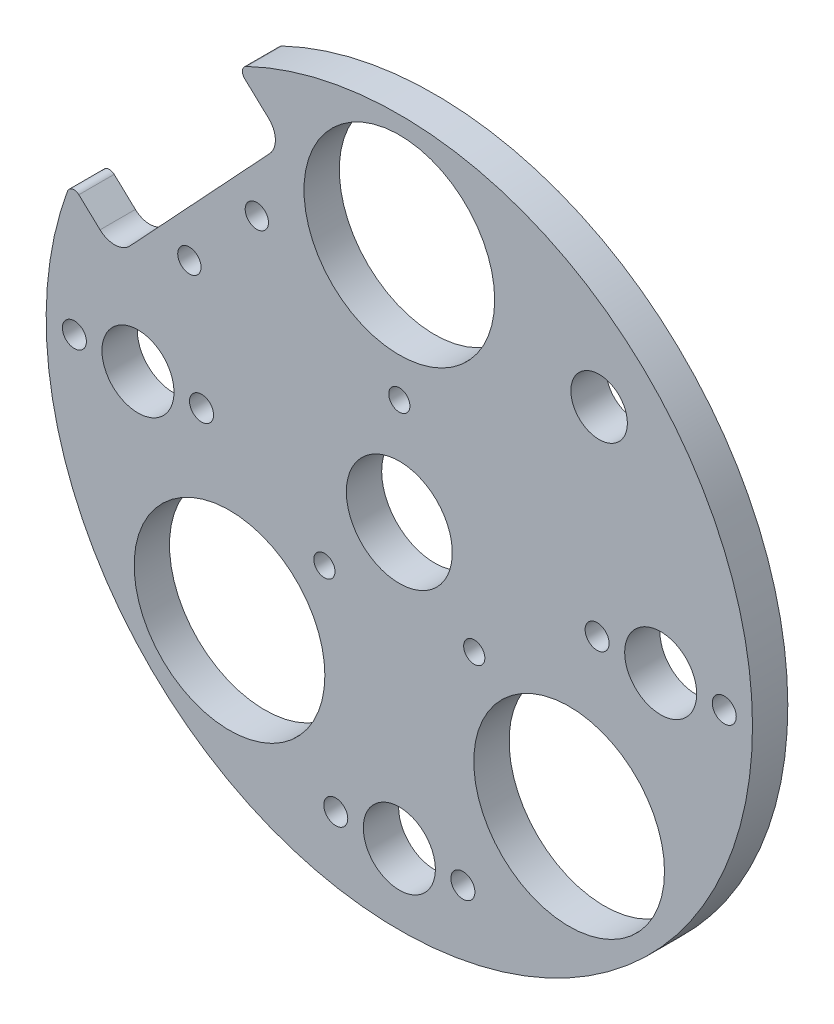
from build123d import *

# Parameters (mm, degrees)
SKETCH1_R                    = 50
BOSS_EXTRUDE1_DEPTH          = 5
F_15_0_15_DIAMETER_HOLE1_D   = 15
F_10_2_10_2_DIAMETER_HOLE1_D = 10.2
M3_CLEARANCE_HOLE1_D         = 3.4
SKETCH9_R                    = 13.5
SKETCH9_R_2                  = 1.5
CUT_EXTRUDE1_DEPTH           = 10
SKETCH10_R                   = 1.65
CUT_EXTRUDE2_DEPTH           = 10
SKETCH13_R                   = 4
CUT_EXTRUDE6_DEPTH           = 10
FILLET1_R                    = 1


with BuildPart() as part:
    # Sketch1 → Boss-Extrude1 (new body)
    with BuildSketch(Plane.XY):
        Circle(SKETCH1_R)
    extrude(amount=BOSS_EXTRUDE1_DEPTH)

    # Ø15.0 (15) Diameter Hole1 (through all)
    with Locations(Plane(origin=(0, 0, 0), x_dir=(-1, 0, 0), z_dir=(0, 0, -1))):
        with Locations((0, 0)):
            Hole(F_15_0_15_DIAMETER_HOLE1_D / 2)

    # Ø10.2 (10.2) Diameter Hole1 (through all)
    with Locations(Plane(origin=(0, 0, 0), x_dir=(-1, 0, 0), z_dir=(0, 0, -1))):
        with Locations((37, 0), (-37, 0), (0, -40)):
            Hole(F_10_2_10_2_DIAMETER_HOLE1_D / 2)

    # M3 Clearance Hole1 (through all)
    with Locations(Plane.XY.offset(5)):
        with Locations((46, 0), (28, 0), (9, -40), (-9, -40), (-46, 0), (-28, 0)):
            Hole(M3_CLEARANCE_HOLE1_D / 2)

    # Sketch9 → Cut-Extrude1 (cut)
    with BuildSketch(Plane.XY.offset(5)):
        with Locations((24.04163056, -24.04163056)):
            Circle(SKETCH9_R)
        with Locations((10.606601718, -10.606601718)):
            Circle(SKETCH9_R_2)
        with Locations((-24.04163056, -24.04163056)):
            Circle(SKETCH9_R)
        with Locations((-10.606601718, -10.606601718)):
            Circle(SKETCH9_R_2)
        with Locations((0, 34)):
            Circle(SKETCH9_R)
        with Locations((0, 15)):
            Circle(SKETCH9_R_2)
    extrude(amount=-CUT_EXTRUDE1_DEPTH, mode=Mode.SUBTRACT)

    # Sketch10 → Cut-Extrude2 (cut)
    with BuildSketch(Plane.XY.offset(5)):
        with Locations((-20.17442319, 27.477446333)):
            Circle(SKETCH10_R)
        with Locations((-29.722400231, 17.23849451)):
            Circle(SKETCH10_R)
        with BuildLine():
            Line((-27.274837591, 48.455628221), (-18.498593172, 40.2716479))
            ThreePointArc((-18.498593172, 40.2716479), (-17.546415771, 38.182285285), (-18.350527147, 36.031591715))
            Line((-18.350527147, 36.031591715), (-38.128479589, 14.822334368))
            ThreePointArc((-38.128479589, 14.822334368), (-40.217842204, 13.870156967), (-42.368535774, 14.674268343))
            Line((-42.368535774, 14.674268343), (-51.144780194, 22.858248664))
            Line((-51.144780194, 22.858248664), (-27.274837591, 48.455628221))
        make_face()
    extrude(amount=-CUT_EXTRUDE2_DEPTH, mode=Mode.SUBTRACT)

    # Sketch13 → Cut-Extrude6 (cut)
    with BuildSketch(Plane.XY.offset(5)):
        with Locations((28.284271247, 28.284271247)):
            Circle(SKETCH13_R)
    extrude(amount=-CUT_EXTRUDE6_DEPTH, mode=Mode.SUBTRACT)

    # Fillet1
    fillet1_edges = [part.edges().sort_by_distance(p)[0] for p in [
        (-22.949421323, 44.422112297, 2.5),
        (-46.456878561, 18.486709669, 2.5),
    ]]
    fillet(fillet1_edges, radius=FILLET1_R)


solid = part.part
